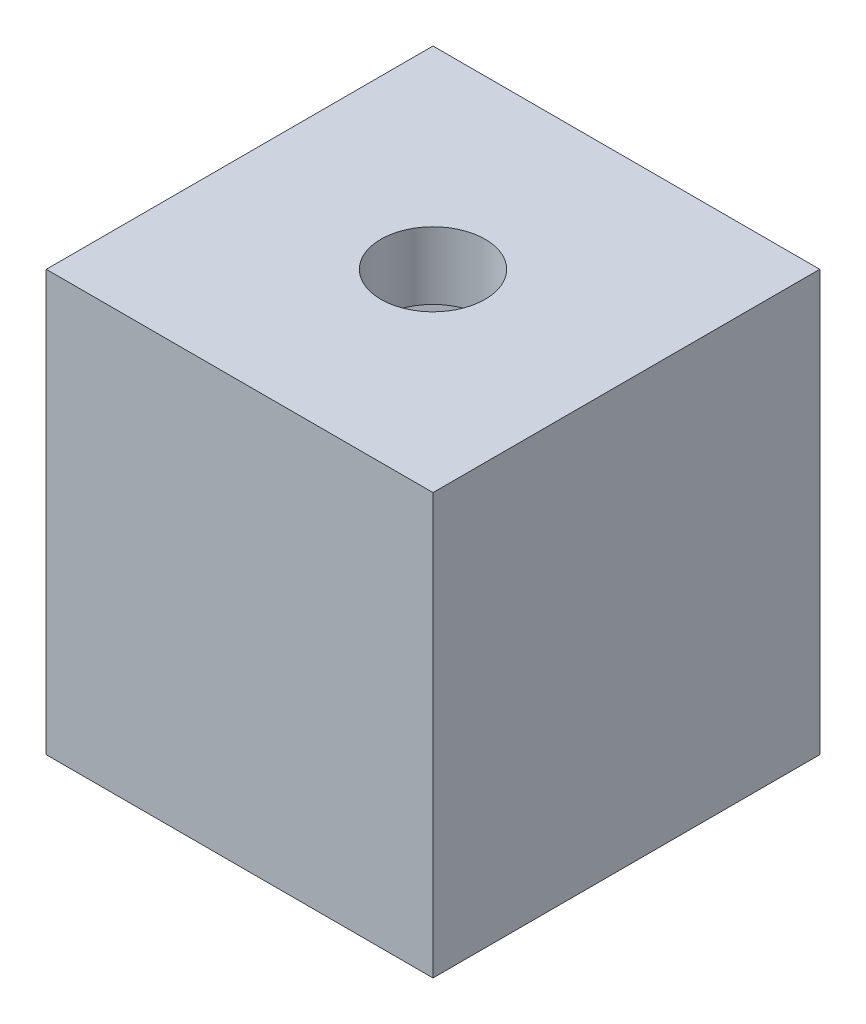
from build123d import *

# Parameters (mm, degrees)
SKETCH3_W           = 11.5
SKETCH3_H           = 11.5
BOSS_EXTRUDE1_DEPTH = 12.5
SKETCH4_R           = 1.55
CUT_EXTRUDE1_DEPTH  = 3
CUT_EXTRUDE2_DEPTH  = 11.5
SKETCH6_W           = 5.3
SKETCH6_H           = 10.5
CUT_EXTRUDE3_DEPTH  = 6.75


with BuildPart() as part:
    # Sketch3 → Boss-Extrude1 (new body)
    with BuildSketch(Plane(origin=(0, 0, 0), x_dir=(1, 0, 0), z_dir=(0, 1, 0))):
        Rectangle(SKETCH3_W, SKETCH3_H)
    extrude(amount=BOSS_EXTRUDE1_DEPTH)

    # Sketch4 → Cut-Extrude1 (cut, through all)
    with BuildSketch(Plane(origin=(0, 10.5, 0), x_dir=(1, 0, 0), z_dir=(0, 1, 0))):
        Circle(SKETCH4_R)
    extrude(amount=CUT_EXTRUDE1_DEPTH, mode=Mode.SUBTRACT)

    # Sketch5 → Cut-Extrude2 (cut, through all)
    with BuildSketch(Plane(origin=(0, 10.5, 0), x_dir=(1, 0, 0), z_dir=(0, 1, 0))):
        Polygon((3.059956427, 0), (1.529978213, 2.65), (-1.529978213, 2.65), (-3.059956427, 0), (-1.529978213, -2.65), (1.529978213, -2.65), align=None)
    extrude(amount=-CUT_EXTRUDE2_DEPTH, mode=Mode.SUBTRACT)

    # Sketch6 → Cut-Extrude3 (cut, through all)
    with BuildSketch(Plane(origin=(0, 0, 0), x_dir=(0, 0, -1), z_dir=(1, 0, 0))):
        with Locations((0, 5.25)):
            Rectangle(SKETCH6_W, SKETCH6_H)
    extrude(amount=-CUT_EXTRUDE3_DEPTH, mode=Mode.SUBTRACT)


solid = part.part
